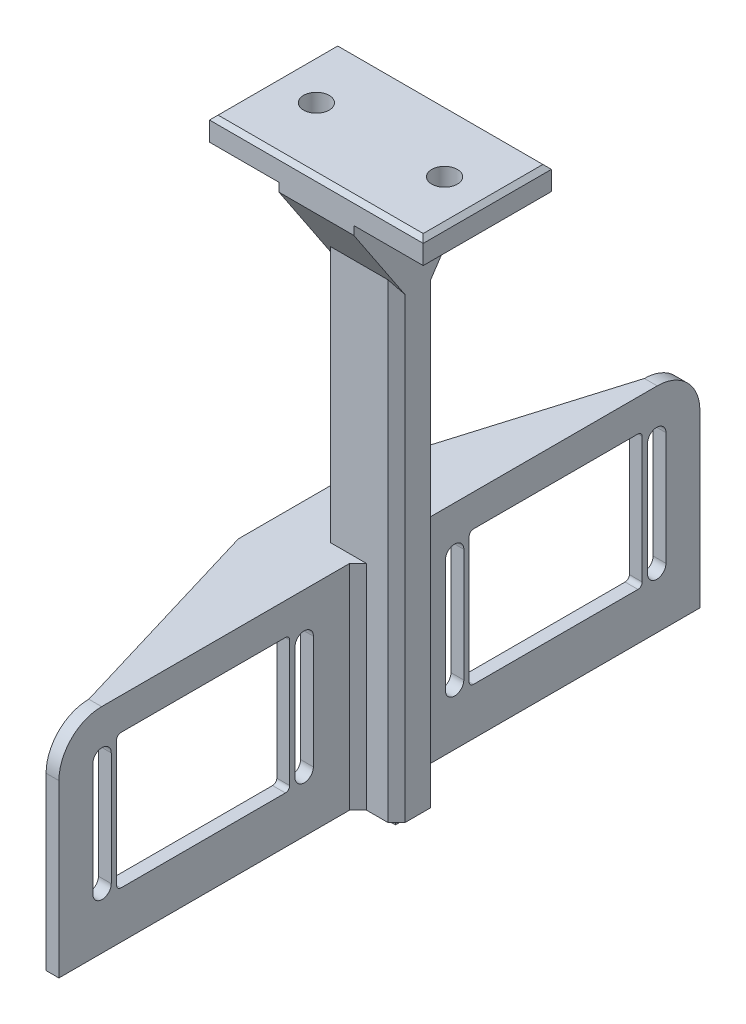
from build123d import *

# Parameters (mm, degrees)
SKETCH_2_W          = 17.5
SKETCH_2_H          = 10
EXTRUDE_1_DEPTH     = 125
SKETCH_3_W          = 50
SKETCH_3_H          = 30
EXTRUDE_2_DEPTH     = 7.5
CHAMFER_1_SIZE      = 1
SKETCH_4_R          = 3
CUT_EXTRUDE_1_DEPTH = 10
EXTRUDE_3_DEPTH     = 17.5
CHAMFER_2_SIZE      = 2
CHAMFER_3_SIZE      = 2
SKETCH_6_W          = 10
SKETCH_6_H          = 3
EXTRUDE_4_DEPTH     = 3.1
SKETCH_7_W          = 70
SKETCH_7_H          = 50
EXTRUDE_5_DEPTH     = 3.25
SKETCH_12_W         = 4.5
SKETCH_12_H         = 6
EXTRUDE_6_DEPTH     = 10
CUT_EXTRUDE_4_DEPTH = 10
SKETCH_15_W         = 70
SKETCH_15_H         = 50
CUT_EXTRUDE_7_DEPTH = 0.25
SKETCH_16_W         = 40.5
SKETCH_16_H         = 31.5
CUT_EXTRUDE_8_DEPTH = 39.25
CHAMFER_7_SIZE      = 2
FILLET_1_R          = 1
FILLET_2_R          = 10
EXTRUDE_7_DEPTH     = 3
CUT_EXTRUDE_9_DEPTH = 48


with BuildPart() as part:
    # 草图2 → 凸台-拉伸1 (new body)
    with BuildSketch(Plane(origin=(0, 0, 0), x_dir=(1, 0, 0), z_dir=(0, 1, 0))):
        with Locations((8.75, 5)):
            Rectangle(SKETCH_2_W, SKETCH_2_H)
    extrude(amount=EXTRUDE_1_DEPTH)

    # 草图3 → 凸台-拉伸2 (add)
    with BuildSketch(Plane(origin=(0, 125, 0), x_dir=(1, 0, 0), z_dir=(0, 1, 0))):
        with Locations((8.75, 5)):
            Rectangle(SKETCH_3_W, SKETCH_3_H)
    extrude(amount=EXTRUDE_2_DEPTH)

    # 倒角1
    chamfer_1_edges = [part.edges().sort_by_distance(p)[0] for p in [
        (33.75, 132.5, -5),
        (8.75, 132.5, -20),
        (-16.25, 132.5, -5),
        (8.75, 132.5, 10),
    ]]
    chamfer(chamfer_1_edges, length=CHAMFER_1_SIZE)

    # 草图4 → 切除-拉伸1 (cut)
    with BuildSketch(Plane(origin=(0, 132.5, 0), x_dir=(1, 0, 0), z_dir=(0, 1, 0))):
        with Locations((23.75, 5)):
            Circle(SKETCH_4_R)
        with Locations((-6.25, 5)):
            Circle(SKETCH_4_R)
    extrude(amount=-CUT_EXTRUDE_1_DEPTH, mode=Mode.SUBTRACT)

    # 草图5 → 凸台-拉伸3 (add)
    with BuildSketch(Plane(origin=(17.5, 0, 0), x_dir=(0, 0, -1), z_dir=(1, 0, 0))):
        Polygon((10, 125), (20, 125), (10, 110), align=None)
        Polygon((0, 125), (-10, 125), (0, 110), align=None)
    extrude(amount=-EXTRUDE_3_DEPTH)

    # 倒角2
    chamfer_2_edges = [part.edges().sort_by_distance(p)[0] for p in [
        (-8.125, 125, -20),
        (33.75, 125, -5),
        (-16.25, 125, -5),
        (-8.125, 125, 10),
        (25.625, 125, -20),
        (25.625, 125, 10),
    ]]
    chamfer(chamfer_2_edges, length=CHAMFER_2_SIZE)

    # 倒角3
    chamfer_3_edges = [part.edges().sort_by_distance(p)[0] for p in [
        (0, 55, -10),
        (17.5, 55, -10),
        (17.5, 55, 0),
        (0, 55, 0),
    ]]
    chamfer(chamfer_3_edges, length=CHAMFER_3_SIZE)

    # 草图6 → 凸台-拉伸4 (add)
    with BuildSketch(Plane.XZ):
        with Locations((8.75, -5)):
            Rectangle(SKETCH_6_W, SKETCH_6_H)
    extrude(amount=EXTRUDE_4_DEPTH)

    # 草图7 → 凸台-拉伸5 (add)
    with BuildSketch(Plane.ZY.offset(-8.75)):
        with Locations((-45, 25)):
            Rectangle(SKETCH_7_W, SKETCH_7_H)
    extrude_5 = extrude(amount=EXTRUDE_5_DEPTH)

    # 镜向1: 凸台-拉伸5 across plane
    add(extrude_5.mirror(Plane(origin=(0, 0, -5), x_dir=(1, 0, 0), z_dir=(0, 0, -1))))

    # 草图12 → 凸台-拉伸6 (add)
    with BuildSketch(Plane(origin=(0, 0, -10), x_dir=(-1, 0, 0), z_dir=(0, 0, -1))):
        with Locations((-17.75, 3)):
            Rectangle(SKETCH_12_W, SKETCH_12_H)
    extrude_6 = extrude(amount=-EXTRUDE_6_DEPTH)

    # 镜向2: 凸台-拉伸6 across plane
    add(extrude_6.mirror(Plane.ZY.offset(-8.75)))

    # 草图13 → 切除-拉伸4 (cut)
    with BuildSketch(Plane(origin=(0, 6, 0), x_dir=(1, 0, 0), z_dir=(0, 1, 0))):
        Polygon((17.5, 8), (17.5, 2), (15.5, 0), (20, 0), (20, 10), (15.5, 10), align=None)
    extrude(amount=-CUT_EXTRUDE_4_DEPTH, mode=Mode.SUBTRACT)

    # 草图15 → 切除-拉伸7 (cut)
    with BuildSketch(Plane(origin=(8.75, 0, 0), x_dir=(0, 0, -1), z_dir=(1, 0, 0))):
        with Locations((-35, 25)):
            Rectangle(SKETCH_15_W, SKETCH_15_H)
        with Locations((45, 25)):
            Rectangle(SKETCH_15_W, SKETCH_15_H)
    extrude(amount=-CUT_EXTRUDE_7_DEPTH, mode=Mode.SUBTRACT)

    # 草图16 → 切除-拉伸8 (cut)
    with BuildSketch(Plane.ZY.offset(-5.5)):
        with Locations((-46.25, 26.75)):
            Rectangle(SKETCH_16_W, SKETCH_16_H)
        with Locations((36.25, 26.75)):
            Rectangle(SKETCH_16_W, SKETCH_16_H)
    extrude(amount=-CUT_EXTRUDE_8_DEPTH, mode=Mode.SUBTRACT)

    # 倒角7
    chamfer_7_edges = [part.edges().sort_by_distance(p)[0] for p in [
        (5.5, 25, -10),
        (5.5, 25, 0),
        (8.5, 25, 0),
        (8.5, 25, -10),
    ]]
    chamfer(chamfer_7_edges, length=CHAMFER_7_SIZE)

    # 圆角1
    fillet_1_edges = [part.edges().sort_by_distance(p)[0] for p in [
        (7, 42.5, -26),
        (7, 11, -26),
        (7, 11, -66.5),
        (7, 42.5, -66.5),
        (7, 11, 16),
        (7, 42.5, 16),
        (7, 42.5, 56.5),
        (7, 11, 56.5),
    ]]
    fillet(fillet_1_edges, radius=FILLET_1_R)

    # 圆角2
    fillet_2_edges = [part.edges().sort_by_distance(p)[0] for p in [
        (7, 50, -80),
        (7, 50, 70),
    ]]
    fillet(fillet_2_edges, radius=FILLET_2_R)

    # 草图17 → 凸台-拉伸7 (add)
    with BuildSketch(Plane(origin=(0, 50, 0), x_dir=(1, 0, 0), z_dir=(0, 1, 0))):
        Polygon((5.5, 70), (-9.5, 20), (-9.5, -10), (5.5, -60), align=None)
    extrude(amount=-EXTRUDE_7_DEPTH)

    # 草图18 → 切除-拉伸9 (cut)
    with BuildSketch(Plane.ZY.offset(-5.5)):
        with BuildLine():
            Line((62.05, 39.5), (62.05, 13))
            ThreePointArc((62.05, 13), (59.9, 10.85), (57.75, 13))
            Line((57.75, 13), (57.75, 39.5))
            ThreePointArc((57.75, 39.5), (59.9, 41.65), (62.05, 39.5))
        make_face()
        with BuildLine():
            Line((10.45, 39.5), (10.45, 13))
            ThreePointArc((10.45, 13), (12.6, 10.85), (14.75, 13))
            Line((14.75, 13), (14.75, 39.5))
            ThreePointArc((14.75, 39.5), (12.6, 41.65), (10.45, 39.5))
        make_face()
        with BuildLine():
            Line((-20.45, 39.5), (-20.45, 13))
            ThreePointArc((-20.45, 13), (-22.6, 10.85), (-24.75, 13))
            Line((-24.75, 13), (-24.75, 39.5))
            ThreePointArc((-24.75, 39.5), (-22.6, 41.65), (-20.45, 39.5))
        make_face()
        with BuildLine():
            Line((-72.05, 39.5), (-72.05, 13))
            ThreePointArc((-72.05, 13), (-69.9, 10.85), (-67.75, 13))
            Line((-67.75, 13), (-67.75, 39.5))
            ThreePointArc((-67.75, 39.5), (-69.9, 41.65), (-72.05, 39.5))
        make_face()
    extrude(amount=-CUT_EXTRUDE_9_DEPTH, mode=Mode.SUBTRACT)


solid = part.part
